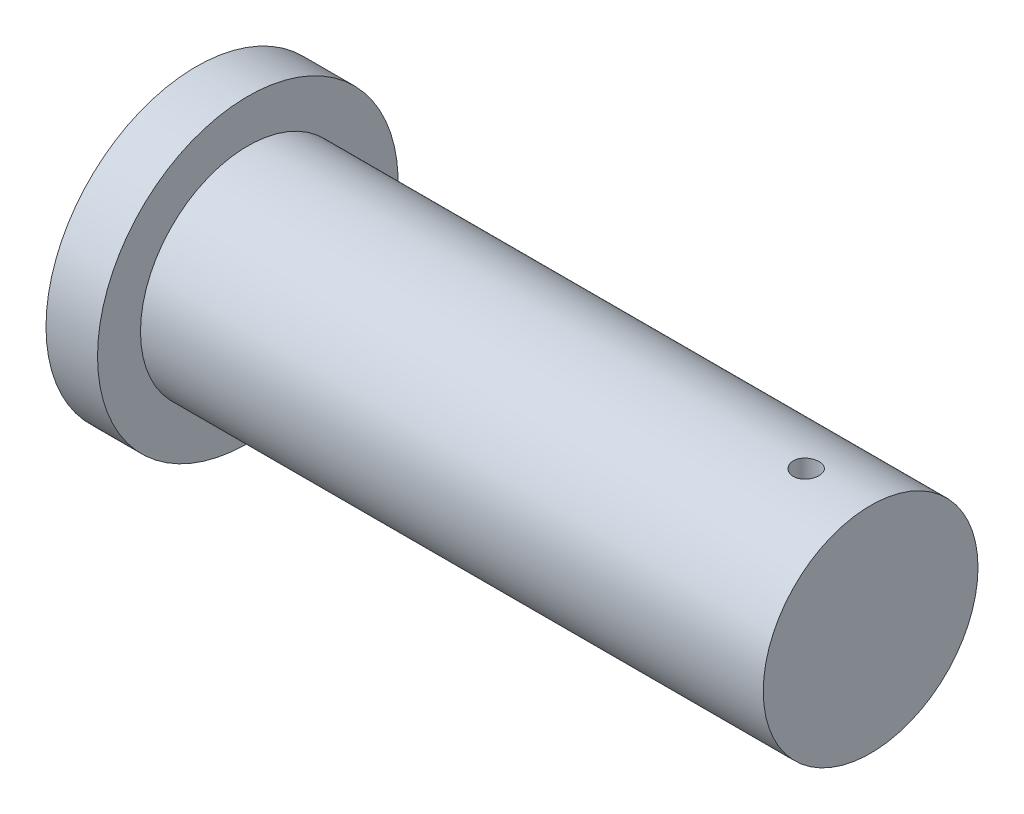
from build123d import *

# Parameters (mm, degrees)
SKETCH3_R               = 30
CUT_EXTRUDE1_DEPTH      = 351
CUT_EXTRUDE1_DEPTH_BACK = 351


with BuildPart() as part:
    # Sketch2 → Revolve1 (revolve)
    with BuildSketch(Plane.XY):
        Polygon((0, 0), (0, 250), (-1450, 250), (-1450, 350), (-1570, 350), (-1570, 0), align=None)
    revolve(axis=Axis((-1570, 0, 0), (1, 0, 0)))

    # Sketch3 → Cut-Extrude1 (cut, two sides)
    with BuildSketch(Plane(origin=(0, 0, 0), x_dir=(1, 0, 0), z_dir=(0, 1, 0))) as cut_extrude1_sk:
        with Locations((-150, 0)):
            Circle(SKETCH3_R)
    extrude(amount=CUT_EXTRUDE1_DEPTH, mode=Mode.SUBTRACT)
    extrude(cut_extrude1_sk.sketch, amount=-CUT_EXTRUDE1_DEPTH_BACK, mode=Mode.SUBTRACT)


solid = part.part
